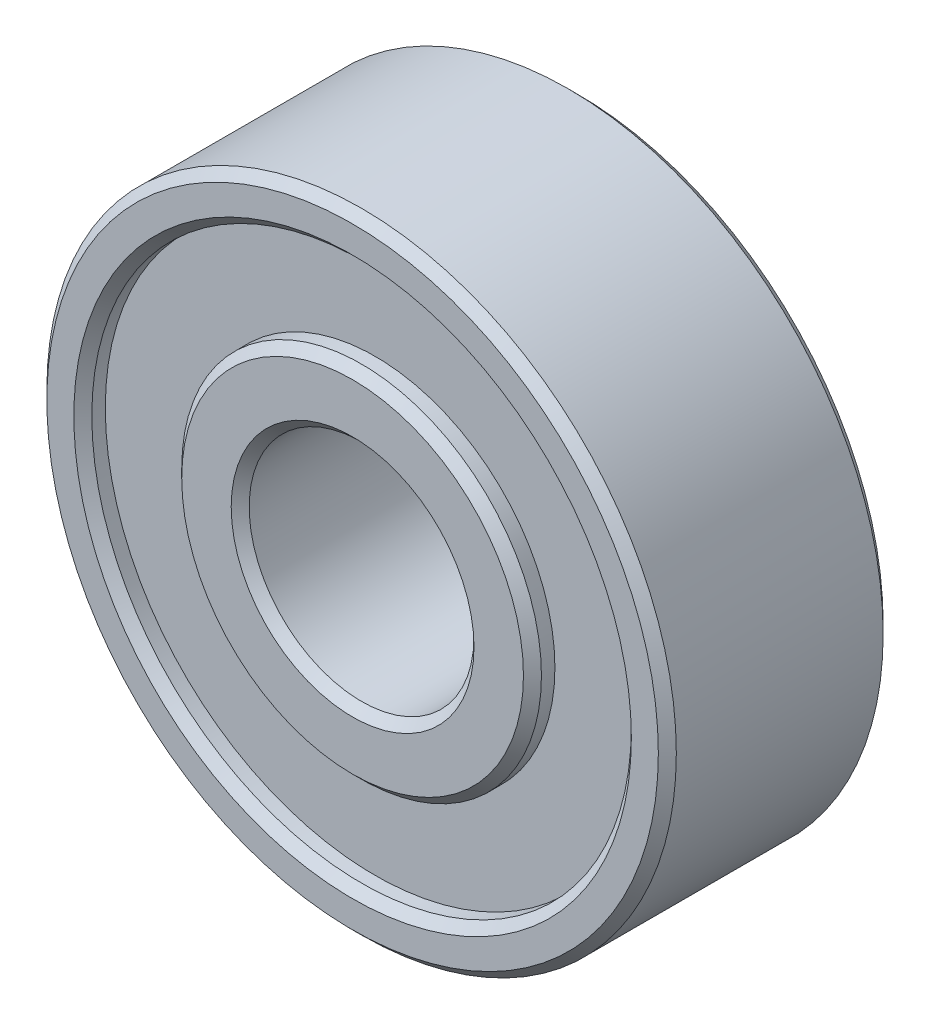
from build123d import *

# Parameters (mm, degrees)
CROQUIS1_R              = 7
SALIENTE_EXTRUIR1_DEPTH = 5
CROQUIS2_R              = 2.5
CORTAR_EXTRUIR1_DEPTH   = 5
CROQUIS3_R              = 6
CROQUIS3_R_2            = 4
CORTAR_EXTRUIR3_DEPTH   = 0.5
CROQUIS4_R              = 6
CROQUIS4_R_2            = 4
CORTAR_EXTRUIR4_DEPTH   = 0.5
CHAFL_N1_SIZE           = 0.2


with BuildPart() as part:
    # Croquis1 → Saliente-Extruir1 (new body)
    with BuildSketch(Plane.XY):
        Circle(CROQUIS1_R)
    extrude(amount=SALIENTE_EXTRUIR1_DEPTH)

    # Croquis2 → Cortar-Extruir1 (cut)
    with BuildSketch(Plane.XY.offset(5)):
        Circle(CROQUIS2_R)
    extrude(amount=-CORTAR_EXTRUIR1_DEPTH, mode=Mode.SUBTRACT)

    # Croquis3 → Cortar-Extruir3 (cut)
    with BuildSketch(Plane.XY.offset(5)):
        Circle(CROQUIS3_R)
        Circle(CROQUIS3_R_2, mode=Mode.SUBTRACT)
    extrude(amount=-CORTAR_EXTRUIR3_DEPTH, mode=Mode.SUBTRACT)

    # Croquis4 → Cortar-Extruir4 (cut)
    with BuildSketch(Plane(origin=(0, 0, 0), x_dir=(-1, 0, 0), z_dir=(0, 0, -1))):
        Circle(CROQUIS4_R)
        Circle(CROQUIS4_R_2, mode=Mode.SUBTRACT)
    extrude(amount=-CORTAR_EXTRUIR4_DEPTH, mode=Mode.SUBTRACT)

    # Chaflán1
    chafl_n1_edges = [part.edges().sort_by_distance(p)[0] for p in [
        (-6, 0, 5),
        (-4, 0, 5),
        (-7, 0, 0),
        (6, 0, 0),
        (4, 0, 0),
        (-7, 0, 5),
        (-2.5, 0, 0),
        (-2.5, 0, 5),
    ]]
    chamfer(chafl_n1_edges, length=CHAFL_N1_SIZE)


solid = part.part
